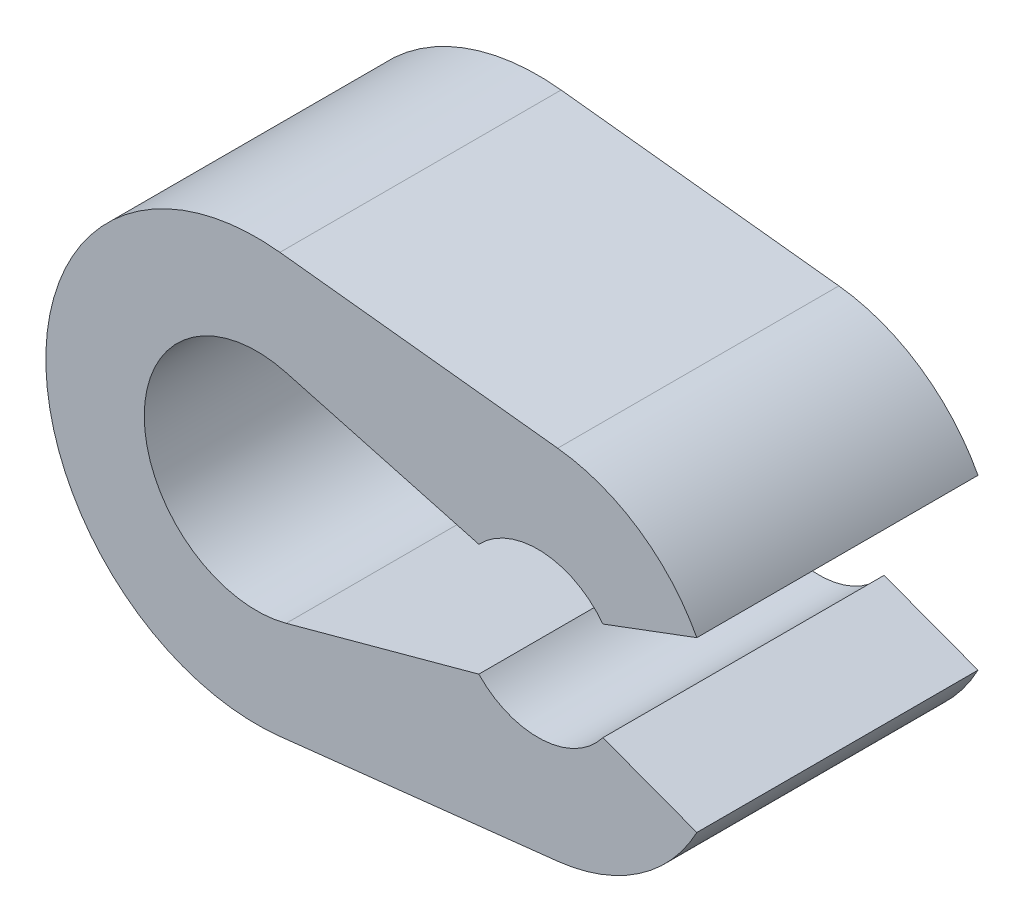
from build123d import *

# Parameters (mm, degrees)
BOSS_EXTRU_1_DEPTH = 10


with BuildPart() as part:
    # Esquisse1 → Boss.-Extru.1 (new body)
    with BuildSketch(Plane.XY):
        with BuildLine():
            Line((0.704, 6.361162158), (-9.175, 7.454486904))
            ThreePointArc((-9.175, 7.454486904), (-17.5, 0), (-9.175, -7.454486904))
            Line((-9.175, -7.454486904), (0.704, -6.361162158))
            ThreePointArc((0.704, -6.361162158), (3.595584036, -5.294504267), (5.65331761, -3))
            Line((5.65331761, -3), (2.312466216, -1.75))
            ThreePointArc((2.312466216, -1.75), (0.16404412, -2.895356546), (-2.1, -2))
            Line((-2.1, -2), (-8.951965066, -3.860262009))
            ThreePointArc((-8.951965066, -3.860262009), (-14, 0), (-8.951965066, 3.860262009))
            Line((-8.951965066, 3.860262009), (-2.1, 2))
            ThreePointArc((-2.1, 2), (0.16404412, 2.895356546), (2.312466216, 1.75))
            Line((2.312466216, 1.75), (5.65331761, 3))
            ThreePointArc((5.65331761, 3), (3.595584036, 5.294504267), (0.704, 6.361162158))
        make_face()
    extrude(amount=BOSS_EXTRU_1_DEPTH)


solid = part.part
